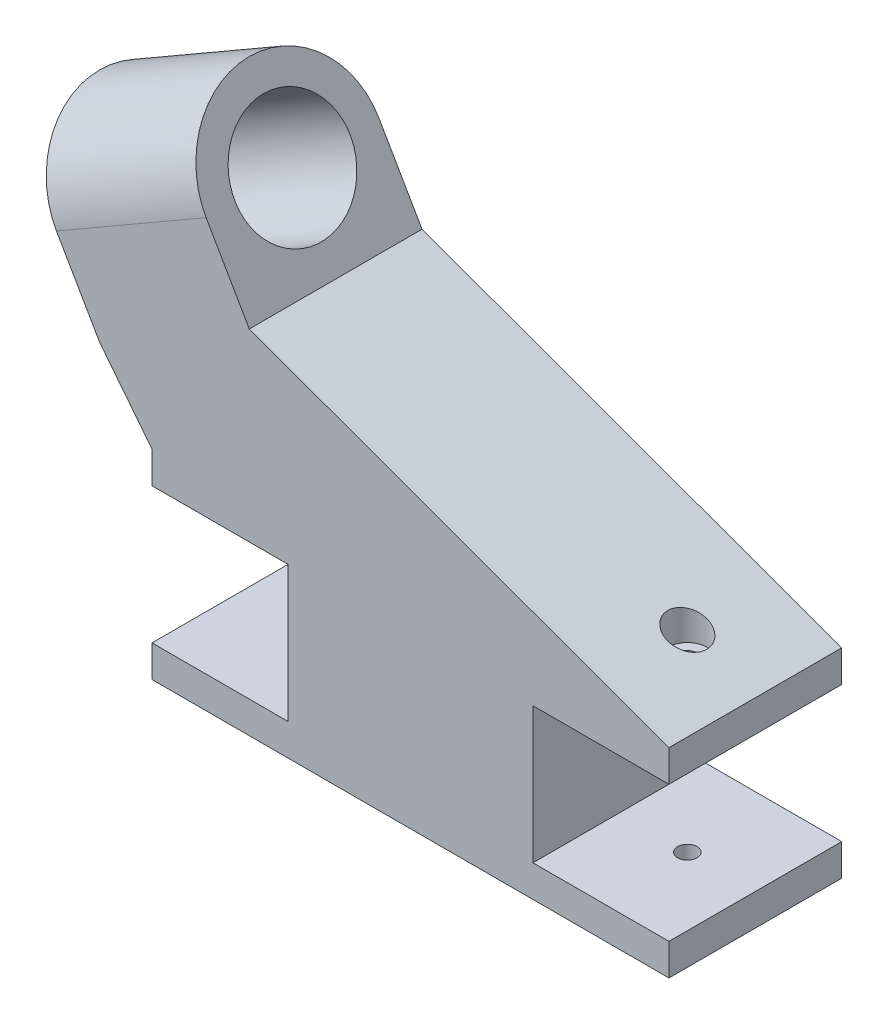
from build123d import *

# Parameters (mm, degrees)
BOSS_EXTRUDE1_DEPTH = 38.1
CUT_EXTRUDE1_DEPTH  = 84.912499942
HOLE3_D             = 25.4
HOLE4_D             = 4.300000036
HOLE4_DEPTH         = 6.99999997


with BuildPart() as part:
    # Sketch7 → Boss-Extrude1 (new body)
    with BuildSketch(Plane.XY):
        Polygon((-87.593351826, 47.625), (-54.597783942, 66.675), (-35.547783942, 33.679432116), (56.999999919, 0), (56.999999919, -6.99999997), (26.999999975, -6.99999997), (26.999999975, -36.999999914), (56.999999919, -36.999999914), (56.999999919, -43.999999884), (-56.999999919, -43.999999884), (-56.999999919, -36.999999914), (-26.999999975, -36.999999914), (-26.999999975, -6.99999997), (-56.999999919, -6.99999997), (-56.999999919, 0), (-68.543351826, 14.629432116), align=None)
    extrude(amount=BOSS_EXTRUDE1_DEPTH)

    # Sketch8 → Cut-Extrude1 (cut, through all)
    with BuildSketch(Plane(origin=(-12.077216058, -6.972783942, 0), x_dir=(0, 0, -1), z_dir=(0.866025404, 0.5, 0))):
        with BuildLine():
            ThreePointArc((-38.1, 65.991135768), (-32.520384182, 79.46151995), (-19.05, 85.041135768))
            Line((-19.05, 85.041135768), (-38.1, 85.041135768))
            Line((-38.1, 85.041135768), (-38.1, 65.991135768))
        make_face()
        with BuildLine():
            Line((0, 65.991135768), (0, 85.041135768))
            Line((0, 85.041135768), (-19.05, 85.041135768))
            ThreePointArc((-19.05, 85.041135768), (-5.579615818, 79.46151995), (0, 65.991135768))
        make_face()
    extrude(amount=-CUT_EXTRUDE1_DEPTH, mode=Mode.SUBTRACT)

    # Hole3 (through all)
    with Locations(Plane(origin=(-12.077216058, -6.972783942, 0), x_dir=(0, 0, -1), z_dir=(0.866025404, 0.5, 0))):
        with Locations((-19.05, 65.991135768)):
            Hole(HOLE3_D / 2)

    # Hole4
    with Locations(Plane.XZ.offset(43.999999884)):
        with Locations((-41.999999947, 19.05), (41.999999947, 19.05)):
            Hole(HOLE4_D / 2, depth=HOLE4_DEPTH)

    # Sketch21 → Hole5 (revolve, cut)
    with BuildSketch(Plane(origin=(41.999999947, -6.99999997, 19.05), x_dir=(0, 0, -1), z_dir=(1, 0, 0))):
        Polygon((0, 0), (0, 73.67499997), (4.300000036, 73.67499997), (4.300000036, 6.99999997), (2.150000018, 6.99999997), (2.150000018, 0), align=None)
    revolve(axis=Axis((41.999999947, 103.00000003, 19.05), (0, -1, 0)), mode=Mode.SUBTRACT)


solid = part.part
